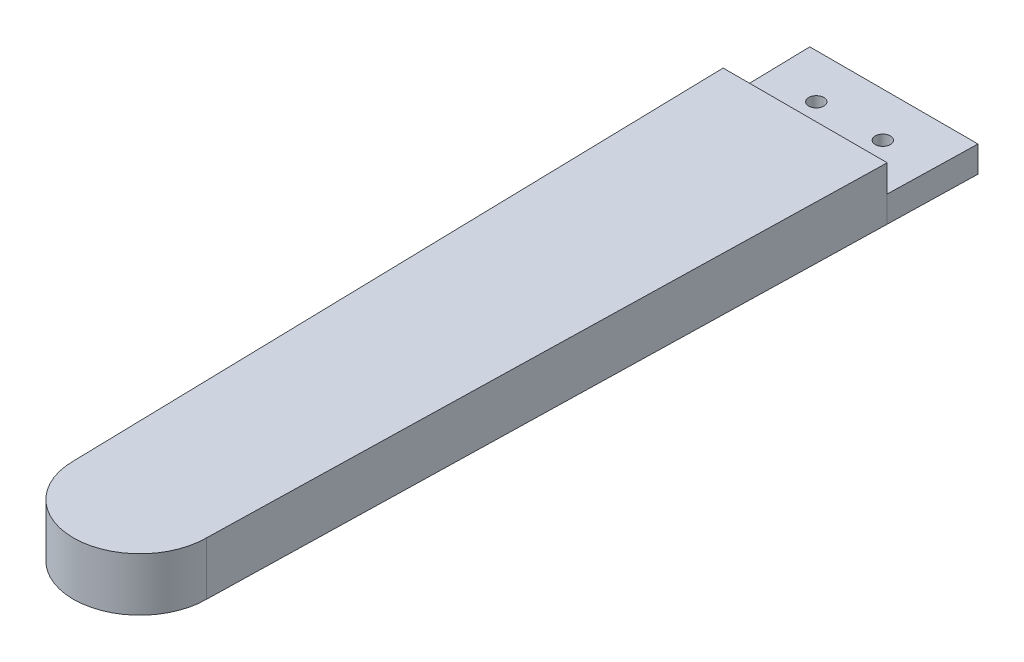
from build123d import *

# Parameters (mm, degrees)
BOSS_EXTRUDE1_DEPTH = 12
BOSS_EXTRUDE2_DEPTH = 5.9
SKETCH3_R           = 1.7
CUT_EXTRUDE1_DEPTH  = 5.9
CUT_EXTRUDE2_DEPTH  = 3


with BuildPart() as part:
    # Sketch1 → Boss-Extrude1 (new body)
    with BuildSketch(Plane(origin=(0, 0, 0), x_dir=(1, 0, 0), z_dir=(0, 1, 0))):
        with BuildLine():
            Line((18.5, 75), (-18.5, 75))
            Line((-18.5, 75), (-15, -75))
            ThreePointArc((-15, -75), (0, -90), (15, -75))
            Line((15, -75), (18.5, 75))
        make_face()
    extrude(amount=BOSS_EXTRUDE1_DEPTH)

    # Sketch2 → Boss-Extrude2 (add)
    with BuildSketch(Plane.XZ):
        Polygon((-18.965, -95), (18.965, -95), (18.5, -75), (-18.5, -75), align=None)
        with BuildLine():
            Line((-18.5, -75), (18.5, -75))
            Line((18.5, -75), (15, 75))
            ThreePointArc((15, 75), (0, 90), (-15, 75))
            Line((-15, 75), (-18.5, -75))
        make_face()
    extrude(amount=-BOSS_EXTRUDE2_DEPTH)

    # Sketch3 → Cut-Extrude1 (cut)
    with BuildSketch(Plane.XZ):
        with Locations((-7.5, -85)):
            Circle(SKETCH3_R)
        with Locations((7.5, -85)):
            Circle(SKETCH3_R)
    extrude(amount=-CUT_EXTRUDE1_DEPTH, mode=Mode.SUBTRACT)

    # Sketch4 → Cut-Extrude2 (cut)
    with BuildSketch(Plane.XZ):
        Polygon((-7.5, -81.766838493), (-10.3, -83.383419246), (-10.3, -86.616580754), (-7.5, -88.233161507), (-4.7, -86.616580754), (-4.7, -83.383419246), align=None)
        Polygon((7.5, -81.766838493), (4.7, -83.383419246), (4.7, -86.616580754), (7.5, -88.233161507), (10.3, -86.616580754), (10.3, -83.383419246), align=None)
    extrude(amount=-CUT_EXTRUDE2_DEPTH, mode=Mode.SUBTRACT)


solid = part.part
